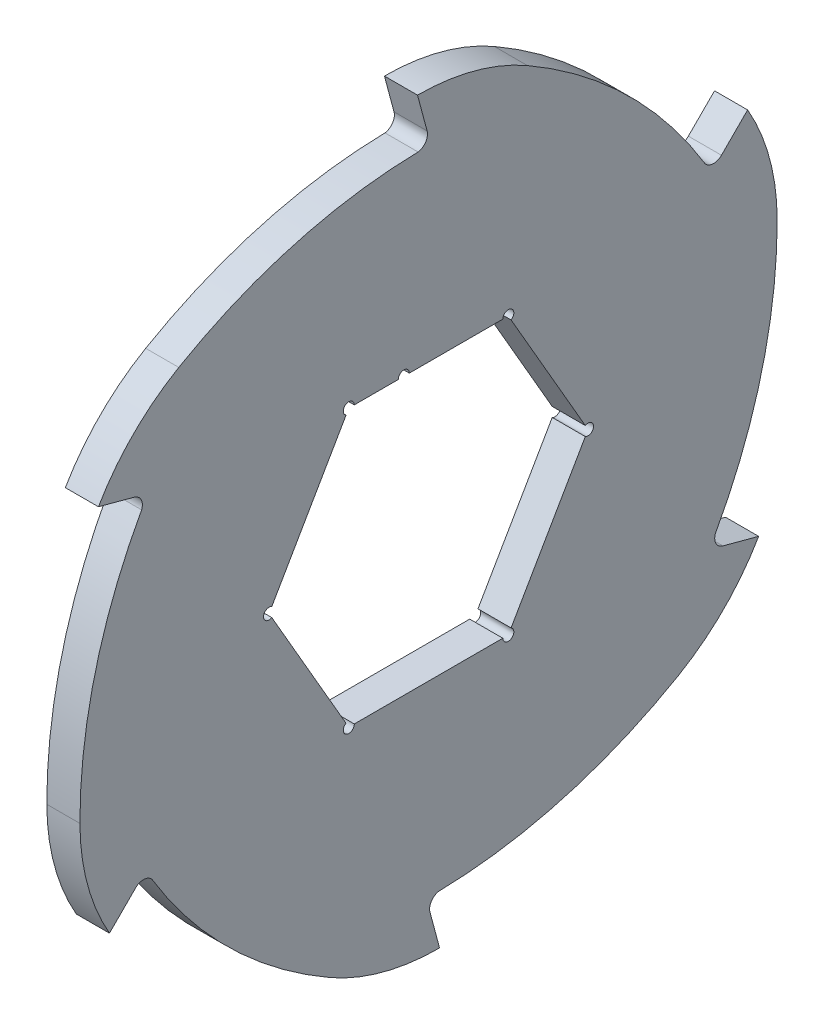
from build123d import *

# Parameters (mm, degrees)
SKETCH1_R                = 59
EXTRUDE1_DEPTH           = 3
EXTRUDE2_DEPTH           = 3
CIRPATTERN1_COUNT        = 6
F_2_0_2_DIAMETER_HOLE1_D = 2
F_2_0_2_DIAMETER_HOLE3_D = 2


with BuildPart() as part:
    # Sketch1 → Extrude1 (new, symmetric)
    with BuildSketch(Plane(origin=(0, 0, 0), x_dir=(0, 0, -1), z_dir=(1, 0, 0))):
        Circle(SKETCH1_R)
        Polygon((14.462624243, 25.05), (-14.462624243, 25.05), (-28.925248486, 0), (-14.462624243, -25.05), (14.462624243, -25.05), (28.925248486, 0), align=None, mode=Mode.SUBTRACT)
    extrude(amount=EXTRUDE1_DEPTH, both=True)

    # Sketch2 → Extrude2 (add, symmetric)
    with BuildSketch(Plane(origin=(0, 0, 0), x_dir=(0, 0, -1), z_dir=(1, 0, 0))):
        with BuildLine():
            Line((-2, 67.961805723), (-0.262709442, 61.478149092))
            ThreePointArc((-0.262709442, 61.478149092), (-0.58620663, 59.77173183), (-2.122608272, 58.961805723))
            ThreePointArc((-2.122608272, 58.961805723), (28.679663449, 51.560419941), (51.21368579, 29.294340542))
            ThreePointArc((51.21368579, 29.294340542), (36.791707484, 48.186627241), (17.927108603, 62.644803614))
            ThreePointArc((17.927108603, 62.644803614), (8.312130826, 66.609702921), (-2, 67.961805723))
        make_face()
    extrude2 = extrude(amount=EXTRUDE2_DEPTH, both=True)

    # CirPattern1: Extrude2 ×6 about axis
    cirpattern1_axis = Axis((0, 0, 0), (1, 0, 0))
    for i in range(1, CIRPATTERN1_COUNT):
        add(extrude2.rotate(cirpattern1_axis, i * 360 / CIRPATTERN1_COUNT))

    # Ø2.0 (2) Diameter Hole1 (through all)
    with Locations(Plane(origin=(3, 0, 0), x_dir=(0, 0, -1), z_dir=(1, 0, 0))):
        with Locations((-14.462624243, 25.05), (14.462624243, 25.05), (28.925248486, 0), (14.462624243, -25.05), (-14.462624243, -25.05), (-28.925248486, 0)):
            Hole(F_2_0_2_DIAMETER_HOLE1_D / 2)

    # Ø2.0 (2) Diameter Hole3 (through all)
    with Locations(Plane(origin=(3, 0, 0), x_dir=(0, 0, -1), z_dir=(1, 0, 0))):
        with Locations((-4.487541414, 25.05)):
            Hole(F_2_0_2_DIAMETER_HOLE3_D / 2)


solid = part.part
